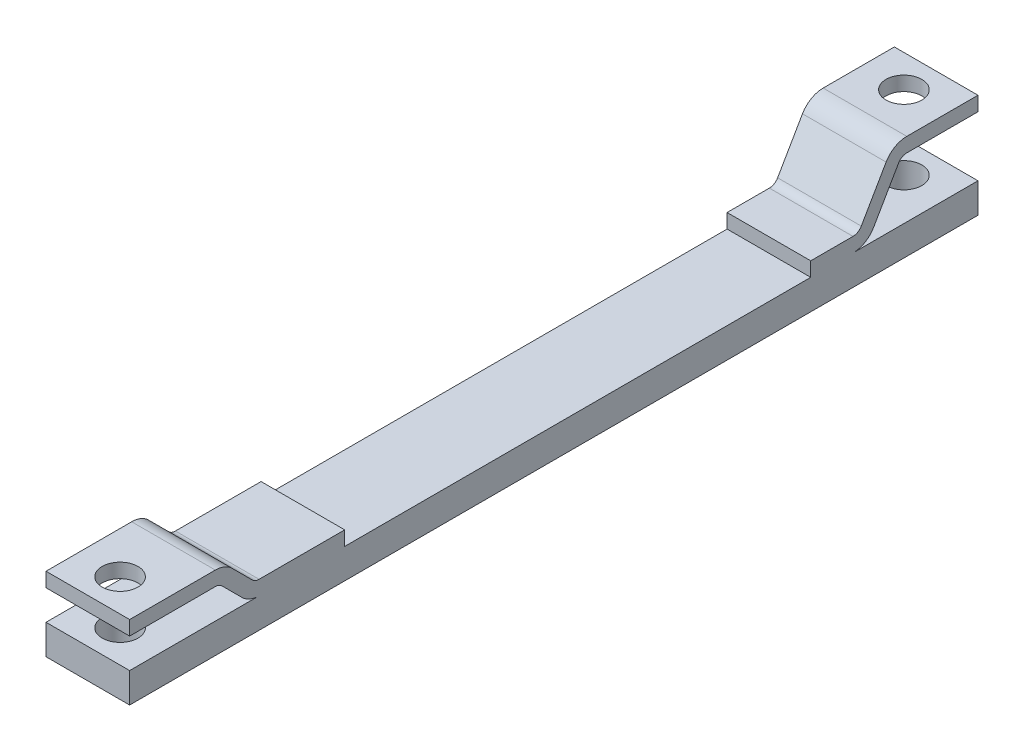
from build123d import *

# Parameters (mm, degrees)
BOSS_EXTRUDE1_DEPTH = 70
SKETCH2_R           = 15
CUT_EXTRUDE1_DEPTH  = 88


with BuildPart() as part:
    # Sketch1 → Boss-Extrude1 (new body)
    with BuildSketch(Plane(origin=(0, 0, 0), x_dir=(0, 0, -1), z_dir=(1, 0, 0))):
        with BuildLine():
            ThreePointArc((94.142135624, 30.857864376), (100.6306026, 26.52240935), (108.284271247, 25))
            Line((108.284271247, 25), (0, 25))
            Line((0, 25), (0, 0))
            Line((0, 0), (710, 0))
            Line((710, 0), (710, 25))
            Line((710, 25), (605.381197846, 25))
            ThreePointArc((605.381197846, 25), (615.381197846, 27.679491924), (622.701705922, 35))
            Line((622.701705922, 35), (643.486315613, 71))
            ThreePointArc((643.486315613, 71), (646.414518843, 73.92820323), (650.414518843, 75))
            Line((650.414518843, 75), (710, 75))
            Line((710, 75), (710, 87))
            Line((710, 87), (650.414518843, 87))
            ThreePointArc((650.414518843, 87), (640.414518843, 84.320508076), (633.094010768, 77))
            Line((633.094010768, 77), (612.309401077, 41))
            ThreePointArc((612.309401077, 41), (609.381197846, 38.07179677), (605.381197846, 37))
            Line((605.381197846, 37), (570, 37))
            Line((570, 37), (570, 25))
            Line((570, 25), (180, 25))
            Line((180, 25), (180, 37))
            Line((180, 37), (108.313708499, 37))
            ThreePointArc((108.313708499, 37), (105.25224104, 37.60896374), (102.656854249, 39.343145751))
            Line((102.656854249, 39.343145751), (85.857864376, 56.142135624))
            ThreePointArc((85.857864376, 56.142135624), (79.3693974, 60.47759065), (71.715728753, 62))
            Line((71.715728753, 62), (0, 62))
            Line((0, 62), (0, 50))
            Line((0, 50), (71.686291501, 50))
            ThreePointArc((71.686291501, 50), (74.74775896, 49.39103626), (77.343145751, 47.656854249))
            Line((77.343145751, 47.656854249), (94.142135624, 30.857864376))
        make_face()
    extrude(amount=BOSS_EXTRUDE1_DEPTH)

    # Sketch2 → Cut-Extrude1 (cut, through all)
    with BuildSketch(Plane(origin=(0, 0, 0), x_dir=(1, 0, 0), z_dir=(0, 1, 0))):
        with Locations((35, 683)):
            Circle(SKETCH2_R)
        with Locations((35, 27)):
            Circle(SKETCH2_R)
    extrude(amount=CUT_EXTRUDE1_DEPTH, mode=Mode.SUBTRACT)


solid = part.part
